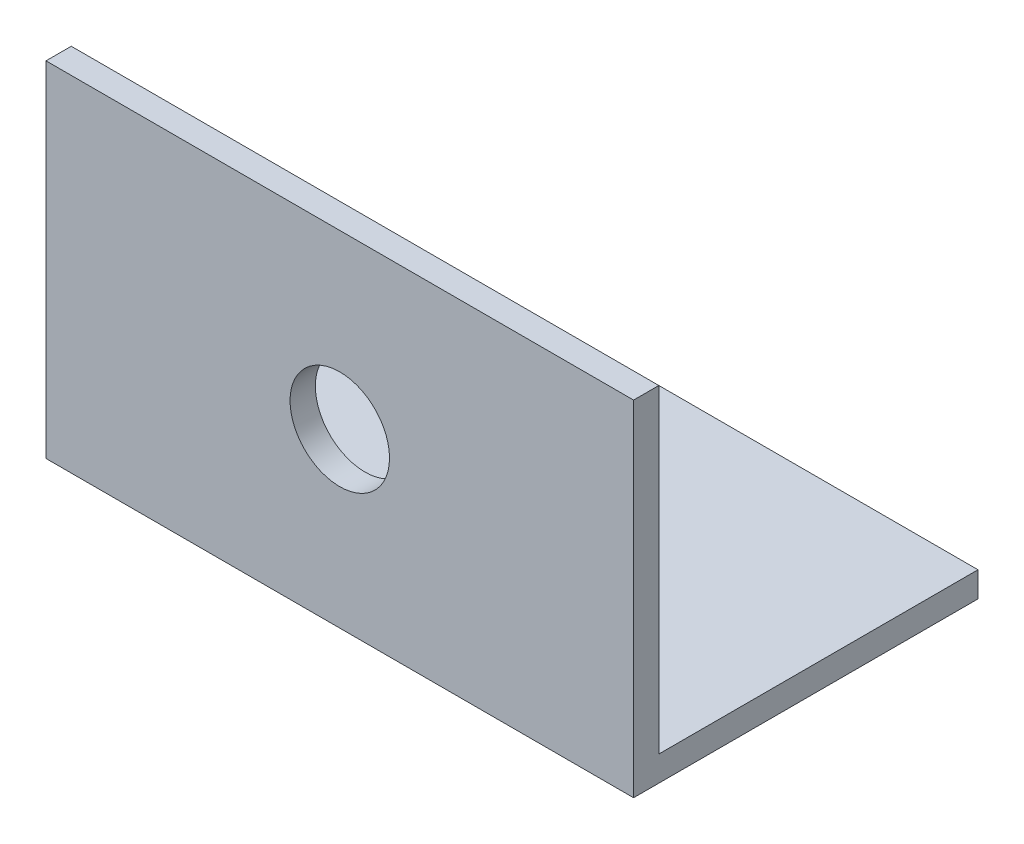
from build123d import *

# Parameters (mm, degrees)
BOSS_EXTRUDE1_DEPTH = 65
SKETCH2_R           = 5.5
CUT_EXTRUDE1_DEPTH  = 65


with BuildPart() as part:
    # Sketch1 → Boss-Extrude1 (new body)
    with BuildSketch(Plane(origin=(0, 0, 0), x_dir=(0, 0, -1), z_dir=(1, 0, 0))):
        Polygon((0, 35.306), (0, 0), (35.306, 0), (35.306, -2.794), (-2.794, -2.794), (-2.794, 35.306), align=None)
    extrude(amount=BOSS_EXTRUDE1_DEPTH)

    # Sketch2 → Cut-Extrude1 (cut)
    with BuildSketch(Plane.XY.offset(2.794)):
        with Locations((32.5, 16.256)):
            Circle(SKETCH2_R)
    extrude(amount=-CUT_EXTRUDE1_DEPTH, mode=Mode.SUBTRACT)


solid = part.part
